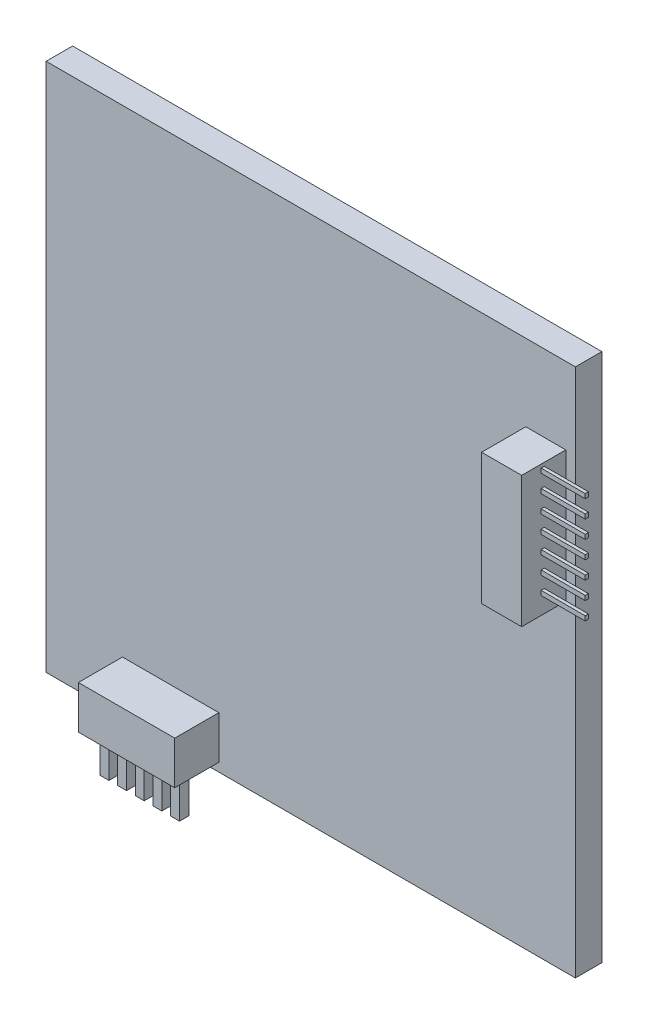
from build123d import *

# Parameters (mm, degrees)
SKETCH2_W           = 60
SKETCH2_H           = 60
BOSS_EXTRUDE1_DEPTH = 3
SKETCH3_W           = 10.924948593
SKETCH3_H           = 4.874207834
SKETCH3_W_2         = 4.538055569
SKETCH3_H_2         = 14.86497051
BOSS_EXTRUDE2_DEPTH = 5
SKETCH4_W           = 1.00253682
SKETCH4_H           = 1.076798806
BOSS_EXTRUDE3_DEPTH = 5
LPATTERN1_COUNT     = 5
LPATTERN1_PITCH     = 2
SKETCH5_W           = 0.358984387
SKETCH5_H           = 0.512834838
BOSS_EXTRUDE4_DEPTH = 5
LPATTERN2_COUNT     = 7
LPATTERN2_PITCH     = 2


with BuildPart() as part:
    # Sketch2 → Boss-Extrude1 (new body)
    with BuildSketch(Plane.XY):
        with Locations((0.566037736, -6.438679245)):
            Rectangle(SKETCH2_W, SKETCH2_H)
    extrude(amount=BOSS_EXTRUDE1_DEPTH)

    # Sketch3 → Boss-Extrude2 (add)
    with BuildSketch(Plane.XY.offset(3)):
        with Locations((-15.317156757, -33.036727165)):
            Rectangle(SKETCH3_W, SKETCH3_H)
        with Locations((27.206104689, 7.432485255)):
            Rectangle(SKETCH3_W_2, SKETCH3_H_2)
    extrude(amount=BOSS_EXTRUDE2_DEPTH)

    # Sketch4 → Boss-Extrude3 (add)
    with BuildSketch(Plane.XZ.offset(35.473831082)):
        with Locations((-19.804086394, 5.472695433)):
            Rectangle(SKETCH4_W, SKETCH4_H)
    boss_extrude3 = extrude(amount=BOSS_EXTRUDE3_DEPTH)

    # LPattern1: Boss-Extrude3 ×5
    with Locations(*[(i * LPATTERN1_PITCH, 0, 0) for i in range(1, LPATTERN1_COUNT)]):
        add(boss_extrude3)

    # Sketch5 → Boss-Extrude4 (add)
    with BuildSketch(Plane(origin=(29.475132473, 0, 0), x_dir=(0, 0, -1), z_dir=(1, 0, 0))):
        with Locations((-5.618353943, 14.22099245)):
            Rectangle(SKETCH5_W, SKETCH5_H)
    boss_extrude4 = extrude(amount=BOSS_EXTRUDE4_DEPTH)

    # LPattern2: Boss-Extrude4 ×7
    with Locations(*[(0, -i * LPATTERN2_PITCH, 0) for i in range(1, LPATTERN2_COUNT)]):
        add(boss_extrude4)


solid = part.part
